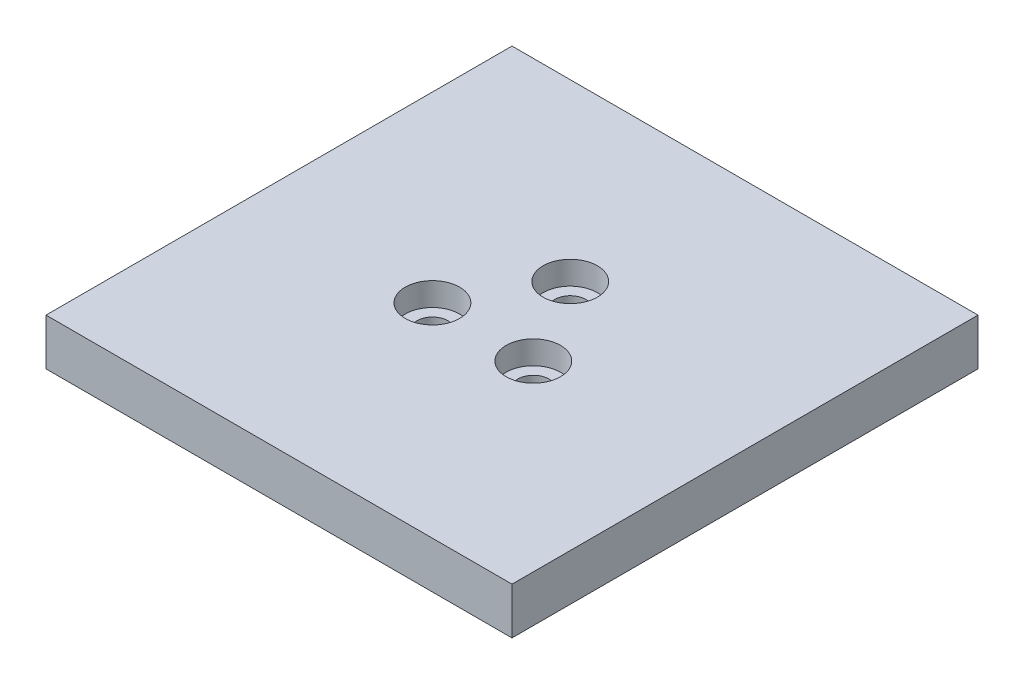
from build123d import *

# Parameters (mm, degrees)
SKETCH1_W           = 60
SKETCH1_H           = 60
BOSS_EXTRUDE2_DEPTH = 6
SKETCH1_4_R         = 2
CUT_EXTRUDE1_DEPTH  = 7
CUT_EXTRUDE2_START  = 6
SKETCH1_5_R         = 3.5
CUT_EXTRUDE2_DEPTH  = 3


with BuildPart() as part:
    # Sketch1 → Boss-Extrude2 (new body)
    with BuildSketch(Plane(origin=(0, 0, 0), x_dir=(1, 0, 0), z_dir=(0, 1, 0))):
        Rectangle(SKETCH1_W, SKETCH1_H)
    extrude(amount=BOSS_EXTRUDE2_DEPTH)

    # Sketch1_4 → Cut-Extrude1 (cut, through all)
    with BuildSketch(Plane(origin=(0, 0, 0), x_dir=(1, 0, 0), z_dir=(0, 1, 0))):
        with Locations((0, 7.5)):
            Circle(SKETCH1_4_R)
        with Locations((6.495190528, -3.75)):
            Circle(SKETCH1_4_R)
        with Locations((-6.495190528, -3.75)):
            Circle(SKETCH1_4_R)
    extrude(amount=CUT_EXTRUDE1_DEPTH, mode=Mode.SUBTRACT)

    # Sketch1_5 → Cut-Extrude2 (cut)
    with BuildSketch(Plane(origin=(0, 0, 0), x_dir=(1, 0, 0), z_dir=(0, 1, 0)).offset(CUT_EXTRUDE2_START)):
        with Locations((0, 7.5)):
            Circle(SKETCH1_5_R)
        with Locations((6.495190528, -3.75)):
            Circle(SKETCH1_5_R)
        with Locations((-6.495190528, -3.75)):
            Circle(SKETCH1_5_R)
    extrude(amount=-CUT_EXTRUDE2_DEPTH, mode=Mode.SUBTRACT)


solid = part.part
